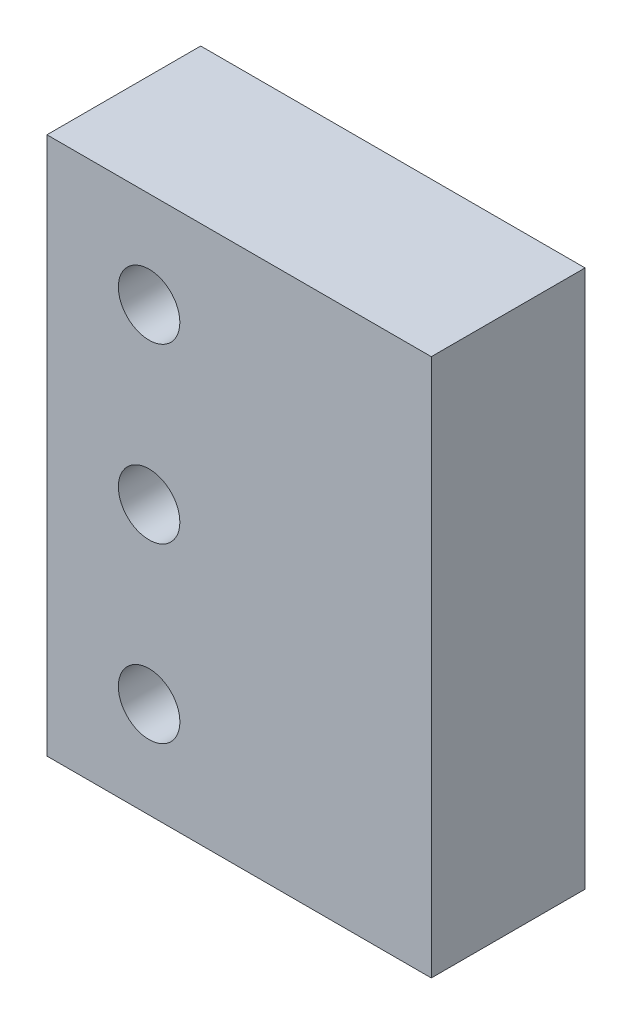
from build123d import *

# Parameters (mm, degrees)
SKETCH1_W           = 50
SKETCH1_H           = 70
SKETCH1_R           = 4
BOSS_EXTRUDE1_DEPTH = 10


with BuildPart() as part:
    # Sketch1 → Boss-Extrude1 (new body, symmetric)
    with BuildSketch(Plane.XY):
        Rectangle(SKETCH1_W, SKETCH1_H)
        with Locations((-11.712149785, 0)):
            Circle(SKETCH1_R, mode=Mode.SUBTRACT)
        with Locations((-11.712149785, 22.5)):
            Circle(SKETCH1_R, mode=Mode.SUBTRACT)
        with Locations((-11.712149785, -22.5)):
            Circle(SKETCH1_R, mode=Mode.SUBTRACT)
    extrude(amount=BOSS_EXTRUDE1_DEPTH, both=True)


solid = part.part
